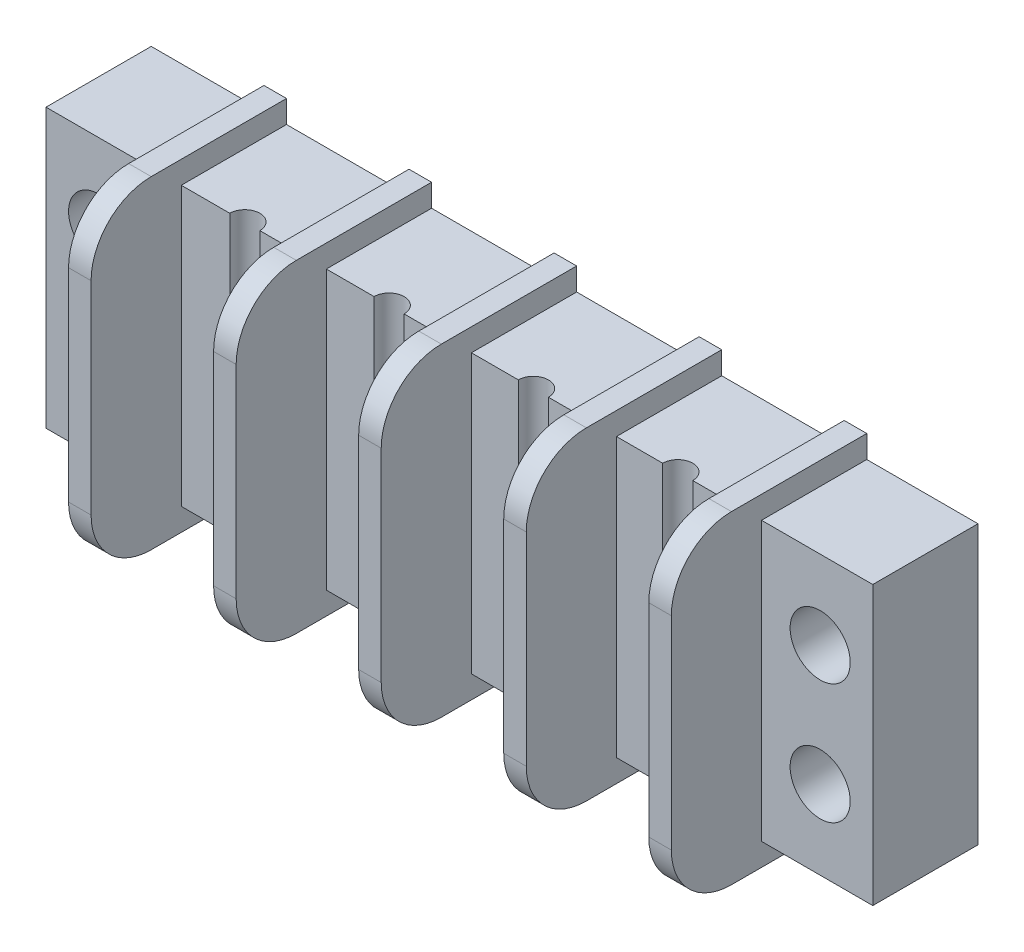
from build123d import *

# Parameters (mm, degrees)
ESQUISSE1_W                = 55
ESQUISSE1_H                = 18.5
BOSS_EXTRU_1_DEPTH         = 7
ENL_V_MAT_EXTRU_1_REACH    = 9
ESQUISSE2_R                = 2
ESQUISSE3_W                = 1.5
ESQUISSE3_H                = 21.5
BOSS_EXTRU_2_DEPTH         = 13
CONG_1_R                   = 4
ESQUISSE4_R                = 1
ENL_V_MAT_EXTRU_2_DEPTH    = 18.5
R_P_TITION_LIN_AIRE1_COUNT = 4
R_P_TITION_LIN_AIRE1_PITCH = 9.6


with BuildPart() as part:
    # Esquisse1 → Boss.-Extru.1 (new body)
    with BuildSketch(Plane.XY):
        with Locations((-1.745283019, 3.839622642)):
            Rectangle(ESQUISSE1_W, ESQUISSE1_H)
    extrude(amount=BOSS_EXTRU_1_DEPTH)

    # Esquisse2 → Enlèv. mat.-Extru.1 (cut, up to next)
    with BuildSketch(Plane(origin=(0, 0, 0), x_dir=(-1, 0, 0), z_dir=(0, 0, -1)), mode=Mode.PRIVATE) as enl_v_mat_extru_1_sk1:
        with Locations((-22.254716981, 7.839622642)):
            Circle(ESQUISSE2_R)
    enl_v_mat_extru_1_tool1 = extrude(enl_v_mat_extru_1_sk1.sketch, amount=-ENL_V_MAT_EXTRU_1_REACH, mode=Mode.PRIVATE) & part.part
    add(enl_v_mat_extru_1_tool1.solids().sort_by_distance((22.254717, 7.839623, 0))[0], mode=Mode.SUBTRACT)
    # Esquisse2 → Enlèv. mat.-Extru.1 (cut, up to next)
    with BuildSketch(Plane(origin=(0, 0, 0), x_dir=(-1, 0, 0), z_dir=(0, 0, -1)), mode=Mode.PRIVATE) as enl_v_mat_extru_1_sk2:
        with Locations((-22.254716981, -0.160377358)):
            Circle(ESQUISSE2_R)
    enl_v_mat_extru_1_tool2 = extrude(enl_v_mat_extru_1_sk2.sketch, amount=-ENL_V_MAT_EXTRU_1_REACH, mode=Mode.PRIVATE) & part.part
    add(enl_v_mat_extru_1_tool2.solids().sort_by_distance((22.254717, -0.160377, 0))[0], mode=Mode.SUBTRACT)
    # Esquisse2 → Enlèv. mat.-Extru.1 (cut, up to next)
    with BuildSketch(Plane(origin=(0, 0, 0), x_dir=(-1, 0, 0), z_dir=(0, 0, -1)), mode=Mode.PRIVATE) as enl_v_mat_extru_1_sk3:
        with Locations((25.745283019, -0.160377358)):
            Circle(ESQUISSE2_R)
    enl_v_mat_extru_1_tool3 = extrude(enl_v_mat_extru_1_sk3.sketch, amount=-ENL_V_MAT_EXTRU_1_REACH, mode=Mode.PRIVATE) & part.part
    add(enl_v_mat_extru_1_tool3.solids().sort_by_distance((-25.745283, -0.160377, 0))[0], mode=Mode.SUBTRACT)
    # Esquisse2 → Enlèv. mat.-Extru.1 (cut, up to next)
    with BuildSketch(Plane(origin=(0, 0, 0), x_dir=(-1, 0, 0), z_dir=(0, 0, -1)), mode=Mode.PRIVATE) as enl_v_mat_extru_1_sk4:
        with Locations((25.745283019, 7.839622642)):
            Circle(ESQUISSE2_R)
    enl_v_mat_extru_1_tool4 = extrude(enl_v_mat_extru_1_sk4.sketch, amount=-ENL_V_MAT_EXTRU_1_REACH, mode=Mode.PRIVATE) & part.part
    add(enl_v_mat_extru_1_tool4.solids().sort_by_distance((-25.745283, 7.839623, 0))[0], mode=Mode.SUBTRACT)

    # Esquisse3 → Boss.-Extru.2 (add)
    with BuildSketch(Plane(origin=(0, 0, 0), x_dir=(-1, 0, 0), z_dir=(0, 0, -1))):
        with Locations((20.995283019, 3.839622642)):
            Rectangle(ESQUISSE3_W, ESQUISSE3_H)
        with Locations((11.345283019, 3.839622642)):
            Rectangle(ESQUISSE3_W, ESQUISSE3_H)
        with Locations((1.695283019, 3.839622642)):
            Rectangle(ESQUISSE3_W, ESQUISSE3_H)
        with Locations((-7.954716981, 3.839622642)):
            Rectangle(ESQUISSE3_W, ESQUISSE3_H)
        with Locations((-17.604716981, 3.839622642)):
            Rectangle(ESQUISSE3_W, ESQUISSE3_H)
    extrude(amount=-BOSS_EXTRU_2_DEPTH)

    # Congé1
    cong_1_edges = [part.edges().sort_by_distance(p)[0] for p in [
        (17.604716981, -6.910377358, 13),
        (17.604716981, 14.589622642, 13),
        (-20.995283019, -6.910377358, 13),
        (-20.995283019, 14.589622642, 13),
        (-11.345283019, -6.910377358, 13),
        (-11.345283019, 14.589622642, 13),
        (-1.695283019, -6.910377358, 13),
        (-1.695283019, 14.589622642, 13),
        (7.954716981, -6.910377358, 13),
        (7.954716981, 14.589622642, 13),
    ]]
    fillet(cong_1_edges, radius=CONG_1_R)

    # Esquisse4 → Enlèv. mat.-Extru.2 (cut)
    with BuildSketch(Plane.XZ.offset(5.410377358)):
        with Locations((12.779716981, 7)):
            Circle(ESQUISSE4_R)
    enl_v_mat_extru_2 = extrude(amount=-ENL_V_MAT_EXTRU_2_DEPTH, mode=Mode.SUBTRACT)

    # Répétition linéaire1: Enlèv. mat.-Extru.2 ×4
    with Locations(*[(-i * R_P_TITION_LIN_AIRE1_PITCH, 0, 0) for i in range(1, R_P_TITION_LIN_AIRE1_COUNT)]):
        add(enl_v_mat_extru_2, mode=Mode.SUBTRACT)


solid = part.part
